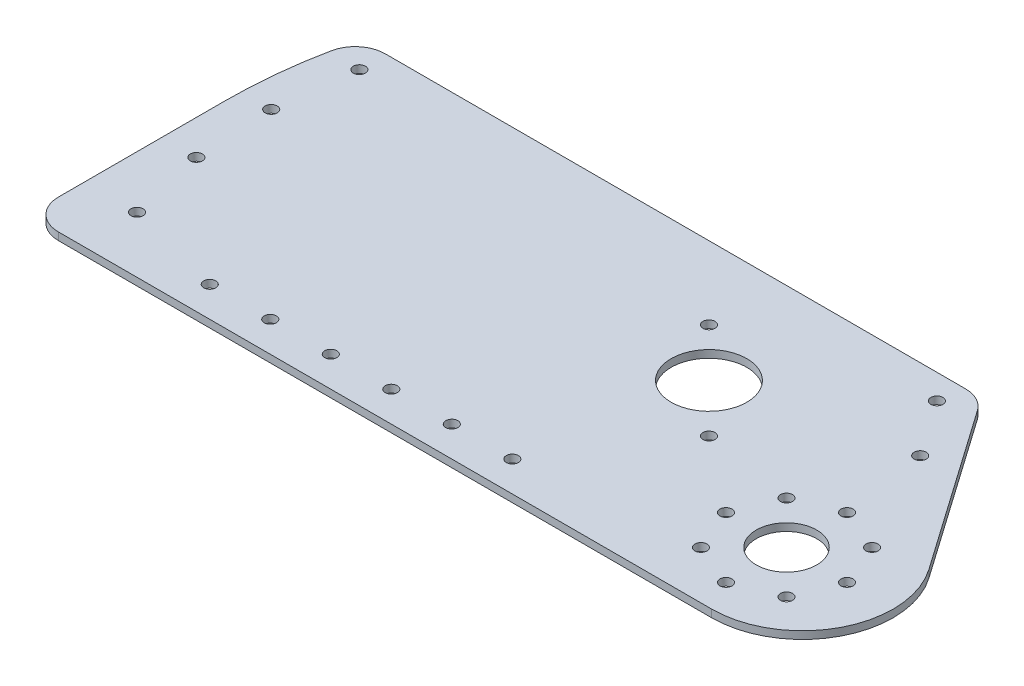
from build123d import *

# Parameters (mm, degrees)
SKETCH1_R                       = 15.875
SKETCH1_R_2                     = 12.7
INITIAL_PLATE_DEPTH             = 3.175
SKETCH2_R                       = 2.54
INITIAL_HOLE_FRONT_DEPTH        = 4.175
FRONT_SUPPORT_MOUNTS_COUNT      = 2
FRONT_SUPPORT_MOUNTS_PITCH      = 28.575
SKETCH3_R                       = 2.54
MAX_PLANETARY_HOLES_DEPTH       = 4.175
MAX_PLANETARY_PATTERN_COUNT     = 3
MAX_PLANETARY_PATTERN_ANGLE     = 180
SKETCH4_R                       = 2.54
INITIAL_STATIC_HOOD_MOUNT_DEPTH = 4.175
HOOD_MOUNTING_PATTERN_COUNT     = 4
HOOD_MOUNTING_PATTERN_ANGLE     = 30
SKETCH5_R                       = 2.54
INITIAL_MOUNTING_HOLE_DEPTH     = 4.175
MOUNTING_PATTERN_COUNT          = 6
MOUNTING_PATTERN_PITCH          = 25.4
SKETCH6_R                       = 2.54
BEARING_RETAINER_MOUNT_DEPTH    = 4.175


with BuildPart() as part:
    # Sketch1 → Initial Plate (new body)
    with BuildSketch(Plane(origin=(0, 0, 0), x_dir=(1, 0, 0), z_dir=(0, 1, 0))):
        with BuildLine():
            Line((-186.6511184, 50.8), (56.888798458, 50.8))
            ThreePointArc((56.888798458, 50.8), (62.753005846, 49.365037581), (67.29202942, 45.384420742))
            Line((67.29202942, 45.384420742), (114.89294907, -22.596737775))
            ThreePointArc((114.89294907, -22.596737775), (117.478368927, -62.042622164), (83.683256183, -82.55))
            Line((83.683256183, -82.55), (-190.5, -82.55))
            ThreePointArc((-190.5, -82.55), (-199.480256121, -78.830256121), (-203.2, -69.85))
            Line((-203.2, -69.85), (-203.2, 0))
            ThreePointArc((-203.2, 0), (-202.171026291, 20.423421079), (-199.094526293, 40.64))
            ThreePointArc((-199.094526293, 40.64), (-194.683303657, 47.937377699), (-186.6511184, 50.8))
        make_face()
        Circle(SKETCH1_R, mode=Mode.SUBTRACT)
        with Locations((76.989658396, -44.45)):
            Circle(SKETCH1_R_2, mode=Mode.SUBTRACT)
    extrude(amount=INITIAL_PLATE_DEPTH)

    # Sketch2 → Initial Hole Front (cut, through all)
    with BuildSketch(Plane(origin=(0, 3.175, 0), x_dir=(1, 0, 0), z_dir=(0, 1, 0))):
        with Locations((55.280583464, 40.396769038)):
            Circle(SKETCH2_R)
    initial_hole_front = extrude(amount=-INITIAL_HOLE_FRONT_DEPTH, mode=Mode.SUBTRACT)

    # Front Support Mounts: Initial Hole Front ×2
    with Locations(*[Vector(0.573576436, 0, 0.819152044) * (i * FRONT_SUPPORT_MOUNTS_PITCH) for i in range(1, FRONT_SUPPORT_MOUNTS_COUNT)]):
        add(initial_hole_front, mode=Mode.SUBTRACT)

    # Sketch3 → Max Planetary Holes (cut, through all)
    with BuildSketch(Plane(origin=(0, 3.175, 0), x_dir=(1, 0, 0), z_dir=(0, 1, 0))):
        with Locations((59.029146154, -26.489487758)):
            Circle(SKETCH3_R)
        with Locations((102.389658396, -44.45)):
            Circle(SKETCH3_R)
        with Locations((94.950170639, -62.410512242)):
            Circle(SKETCH3_R)
        with Locations((51.589658396, -44.45)):
            Circle(SKETCH3_R)
    max_planetary_holes = extrude(amount=-MAX_PLANETARY_HOLES_DEPTH, mode=Mode.SUBTRACT)

    # Max Planetary Pattern: Max Planetary Holes ×3 about axis
    max_planetary_pattern_axis = Axis((76.989658396, 0, 44.45), (0, 1, 0))
    for i in range(1, MAX_PLANETARY_PATTERN_COUNT):
        add(max_planetary_holes.rotate(max_planetary_pattern_axis, i * MAX_PLANETARY_PATTERN_ANGLE / (MAX_PLANETARY_PATTERN_COUNT - 1)), mode=Mode.SUBTRACT)

    # Sketch4 → Initial Static Hood Mount (cut, through all)
    with BuildSketch(Plane(origin=(0, 3.175, 0), x_dir=(1, 0, 0), z_dir=(0, 1, 0))):
        with Locations((-186.339919668, 39.593993711)):
            Circle(SKETCH4_R)
    initial_static_hood_mount = extrude(amount=-INITIAL_STATIC_HOOD_MOUNT_DEPTH, mode=Mode.SUBTRACT)

    # Hood Mounting Pattern: Initial Static Hood Mount ×4 about axis
    hood_mounting_pattern_axis = Axis((0, 0, 0), (0, 1, 0))
    for i in range(1, HOOD_MOUNTING_PATTERN_COUNT):
        add(initial_static_hood_mount.rotate(hood_mounting_pattern_axis, i * HOOD_MOUNTING_PATTERN_ANGLE / (HOOD_MOUNTING_PATTERN_COUNT - 1)), mode=Mode.SUBTRACT)

    # Sketch5 → Initial Mounting Hole (cut, through all)
    with BuildSketch(Plane(origin=(0, 3.175, 0), x_dir=(1, 0, 0), z_dir=(0, 1, 0))):
        with Locations((-139.7, -69.85)):
            Circle(SKETCH5_R)
    initial_mounting_hole = extrude(amount=-INITIAL_MOUNTING_HOLE_DEPTH, mode=Mode.SUBTRACT)

    # Mounting Pattern: Initial Mounting Hole ×6
    with Locations(*[(i * MOUNTING_PATTERN_PITCH, 0, 0) for i in range(1, MOUNTING_PATTERN_COUNT)]):
        add(initial_mounting_hole, mode=Mode.SUBTRACT)

    # Sketch6 → Bearing Retainer Mount (cut, through all)
    with BuildSketch(Plane(origin=(0, 3.175, 0), x_dir=(1, 0, 0), z_dir=(0, 1, 0))):
        with Locations((-20.205576272, 20.205576272)):
            Circle(SKETCH6_R)
        with Locations((20.205576272, -20.205576272)):
            Circle(SKETCH6_R)
    extrude(amount=-BEARING_RETAINER_MOUNT_DEPTH, mode=Mode.SUBTRACT)


solid = part.part
